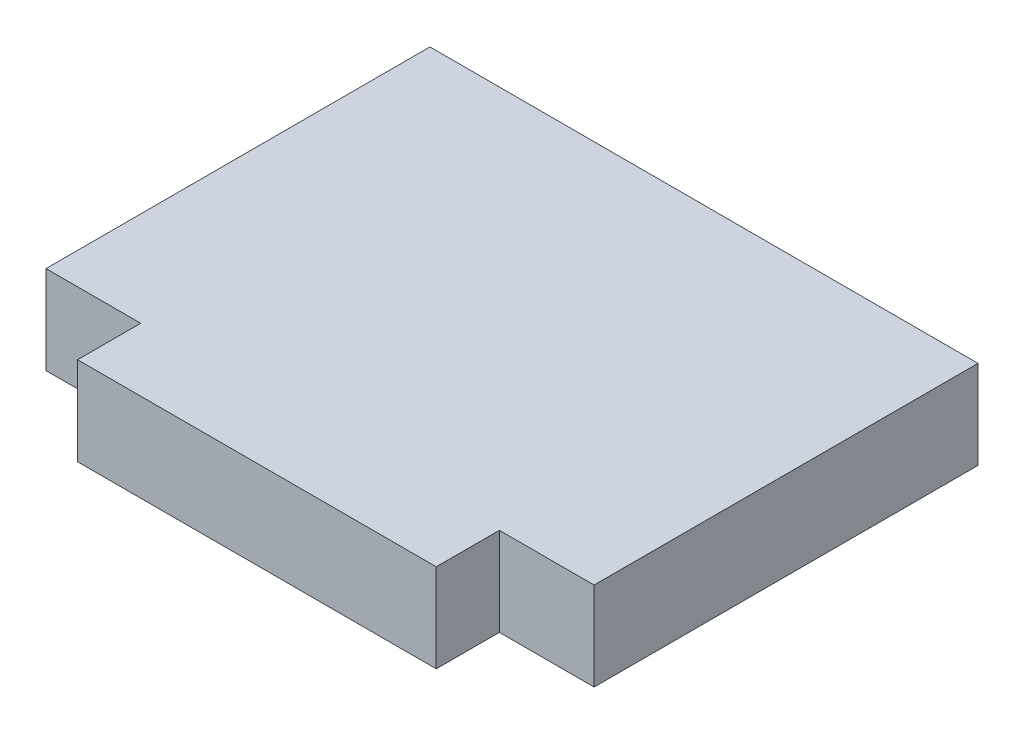
from build123d import *

# Parameters (mm, degrees)
SKETCH1_W           = 110.236
SKETCH1_H           = 89.916
BOSS_EXTRUDE1_DEPTH = 17.78
SKETCH2_W           = 19.05
SKETCH2_H           = 12.7
CUT_EXTRUDE1_DEPTH  = 17.78


with BuildPart() as part:
    # Sketch1 → Boss-Extrude1 (new body)
    with BuildSketch(Plane(origin=(0, 0, 0), x_dir=(1, 0, 0), z_dir=(0, 1, 0))):
        with Locations((0, -19.671907216)):
            Rectangle(SKETCH1_W, SKETCH1_H)
    extrude(amount=BOSS_EXTRUDE1_DEPTH)

    # Sketch2 → Cut-Extrude1 (cut)
    with BuildSketch(Plane(origin=(0, 17.78, 0), x_dir=(1, 0, 0), z_dir=(0, 1, 0))):
        with Locations((-45.593, -58.279907216)):
            Rectangle(SKETCH2_W, SKETCH2_H)
        with Locations((45.593, -58.279907216)):
            Rectangle(SKETCH2_W, SKETCH2_H)
    extrude(amount=-CUT_EXTRUDE1_DEPTH, mode=Mode.SUBTRACT)


solid = part.part
